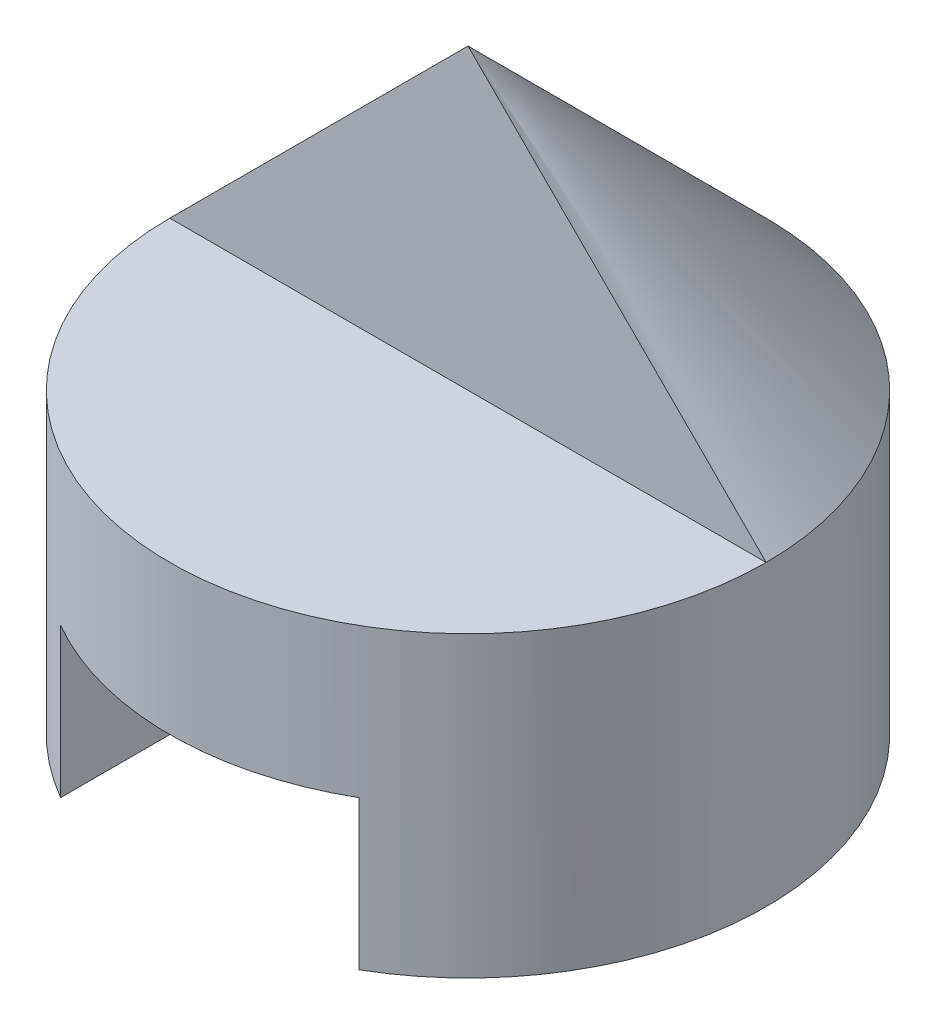
from build123d import *

# Parameters (mm, degrees)
SKETCH1_W           = 40
SKETCH1_H           = 40
BOSS_EXTRUDE1_DEPTH = 40
SKETCH2_W           = 20
SKETCH2_H           = 10
CUT_EXTRUDE1_DEPTH  = 40
CUT_EXTRUDE2_DEPTH  = 40
SKETCH4_W           = 20
SKETCH4_H           = 20
CUT_EXTRUDE5_DEPTH  = 40
SKETCH5_R           = 20
CUT_EXTRUDE6_DEPTH  = 30
REVOLVE1_ANGLE      = 180


with BuildPart() as part:
    # Sketch1 → Boss-Extrude1 (new body)
    with BuildSketch(Plane.XY):
        with Locations((20, 20)):
            Rectangle(SKETCH1_W, SKETCH1_H)
    extrude(amount=BOSS_EXTRUDE1_DEPTH)

    # Sketch2 → Cut-Extrude1 (cut)
    with BuildSketch(Plane.XY.offset(40)):
        with Locations((20, 5)):
            Rectangle(SKETCH2_W, SKETCH2_H)
        Polygon((0, 40), (0, 20), (20, 40), align=None)
        Polygon((20, 40), (40, 20), (40, 40), align=None)
    extrude(amount=-CUT_EXTRUDE1_DEPTH, mode=Mode.SUBTRACT)

    # Sketch3 → Cut-Extrude2 (cut)
    with BuildSketch(Plane(origin=(0, 0, 0), x_dir=(1, 0, 0), z_dir=(0, 1, 0))):
        with BuildLine():
            Line((20, 0), (0, 0))
            Line((0, 0), (0, -20))
            ThreePointArc((0, -20), (5.857864376, -5.857864376), (20, 0))
        make_face()
        with BuildLine():
            Line((40, 0), (20, 0))
            ThreePointArc((20, 0), (34.142135624, -5.857864376), (40, -20))
            Line((40, -20), (40, 0))
        make_face()
        with BuildLine():
            Line((40, -40), (40, -20))
            ThreePointArc((40, -20), (34.142135624, -34.142135624), (20, -40))
            Line((20, -40), (40, -40))
        make_face()
        with BuildLine():
            ThreePointArc((20, -40), (5.857864376, -34.142135624), (0, -20))
            Line((0, -20), (0, -40))
            Line((0, -40), (20, -40))
        make_face()
    extrude(amount=CUT_EXTRUDE2_DEPTH, mode=Mode.SUBTRACT)

    # Sketch4 → Cut-Extrude5 (cut)
    with BuildSketch(Plane(origin=(0, 0, 0), x_dir=(0, 0, -1), z_dir=(1, 0, 0))):
        Polygon((0, 40), (0, 20), (-20, 40), align=None)
        with Locations((-30, 30)):
            Rectangle(SKETCH4_W, SKETCH4_H)
    extrude(amount=CUT_EXTRUDE5_DEPTH, mode=Mode.SUBTRACT)

    # Sketch5 → Cut-Extrude6 (cut)
    with BuildSketch(Plane(origin=(0, 20, 0), x_dir=(1, 0, 0), z_dir=(0, 1, 0))):
        with Locations((20, -20)):
            Circle(SKETCH5_R)
    extrude(amount=CUT_EXTRUDE6_DEPTH, mode=Mode.SUBTRACT)

    # Sketch6 → Revolve1 (revolve)
    with BuildSketch(Plane.XY.offset(20)):
        Polygon((20, 20), (20, 40), (0, 20), align=None)
    revolve(axis=Axis((20, 20, 20), (0, -1, 0)), revolution_arc=REVOLVE1_ANGLE)


solid = part.part
